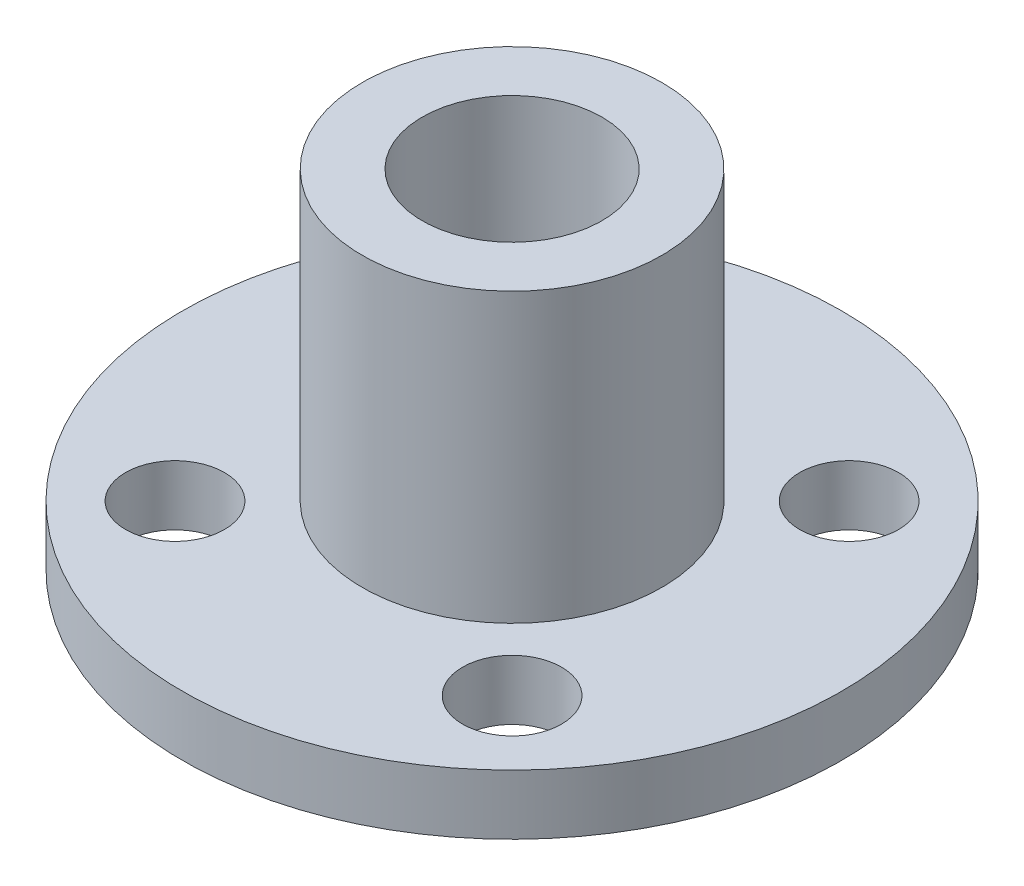
from build123d import *

# Parameters (mm, degrees)
SKETCH_3_R          = 1.65
CUT_EXTRUDE_1_DEPTH = 12.6


with BuildPart() as part:
    # 草图2 → 旋转1 (revolve)
    with BuildSketch(Plane.XY):
        Polygon((3, 11.6), (3, 0), (11, 0), (11, 2), (5, 2), (5, 11.6), align=None)
    revolve(axis=Axis((0, 0, 0), (0, 1, 0)))

    # 草图3 → 切除-拉伸1 (cut, through all)
    with BuildSketch(Plane.XZ):
        with Locations((-5.625, 5.625)):
            Circle(SKETCH_3_R)
        with Locations((5.625, 5.625)):
            Circle(SKETCH_3_R)
        with Locations((5.625, -5.625)):
            Circle(SKETCH_3_R)
        with Locations((-5.625, -5.625)):
            Circle(SKETCH_3_R)
    extrude(amount=-CUT_EXTRUDE_1_DEPTH, mode=Mode.SUBTRACT)


solid = part.part
